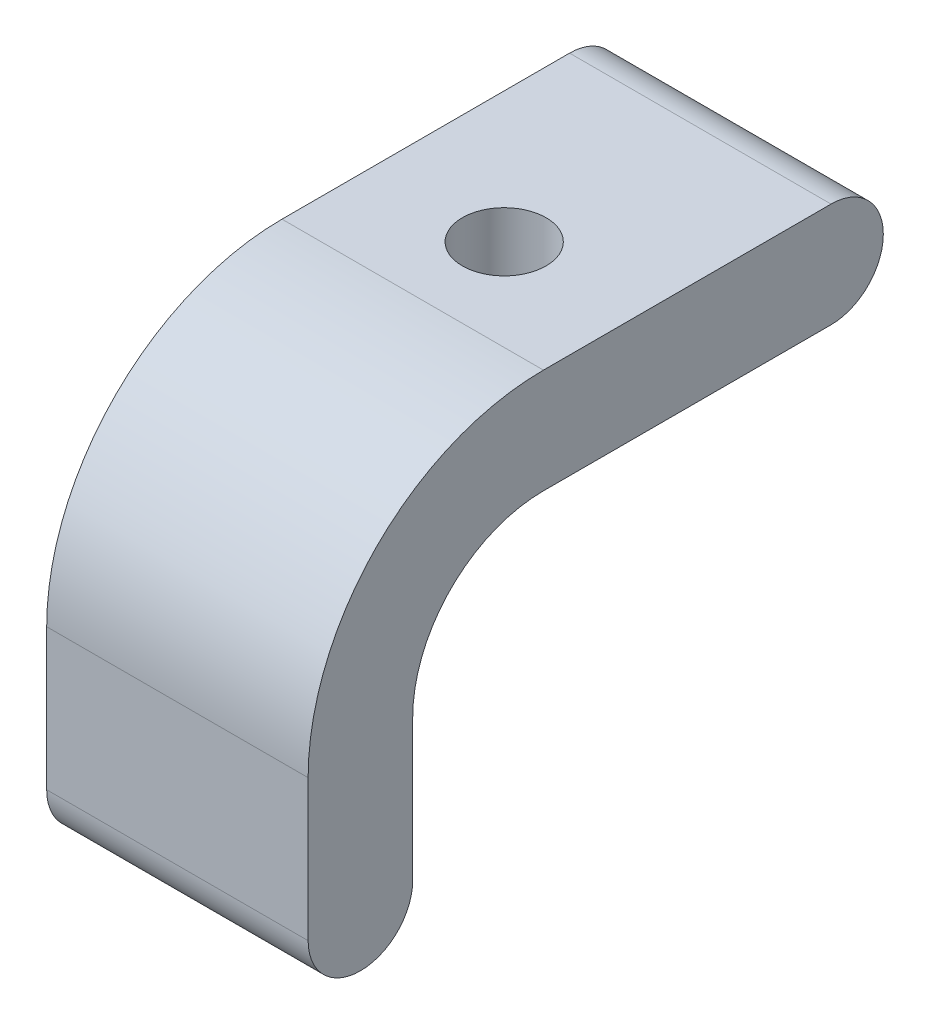
from build123d import *

# Parameters (mm, degrees)
BOSS_EXTRUDE1_DEPTH = 10
SKETCH2_R           = 1.6
CUT_EXTRUDE1_DEPTH  = 10


with BuildPart() as part:
    # Sketch1 → Boss-Extrude1 (new body)
    with BuildSketch(Plane(origin=(0, 0, 0), x_dir=(0, 0, -1), z_dir=(1, 0, 0))):
        with BuildLine():
            Line((0, 0), (11, 0))
            ThreePointArc((11, 0), (13, 2), (11, 4))
            Line((11, 4), (0, 4))
            ThreePointArc((0, 4), (-6.363961031, 1.363961031), (-9, -5))
            Line((-9, -5), (-9, -10.4))
            ThreePointArc((-9, -10.4), (-7, -12.4), (-5, -10.4))
            Line((-5, -10.4), (-5, -5))
            ThreePointArc((-5, -5), (-3.535533906, -1.464466094), (0, 0))
        make_face()
    extrude(amount=BOSS_EXTRUDE1_DEPTH)

    # Sketch2 → Cut-Extrude1 (cut)
    with BuildSketch(Plane(origin=(0, 4, 0), x_dir=(1, 0, 0), z_dir=(0, 1, 0))):
        with Locations(Location((5, 3.5, 0), (0, 0, 270))):  # turned: the seam where the file's is
            Circle(SKETCH2_R)
    extrude(amount=-CUT_EXTRUDE1_DEPTH, mode=Mode.SUBTRACT)


solid = part.part
